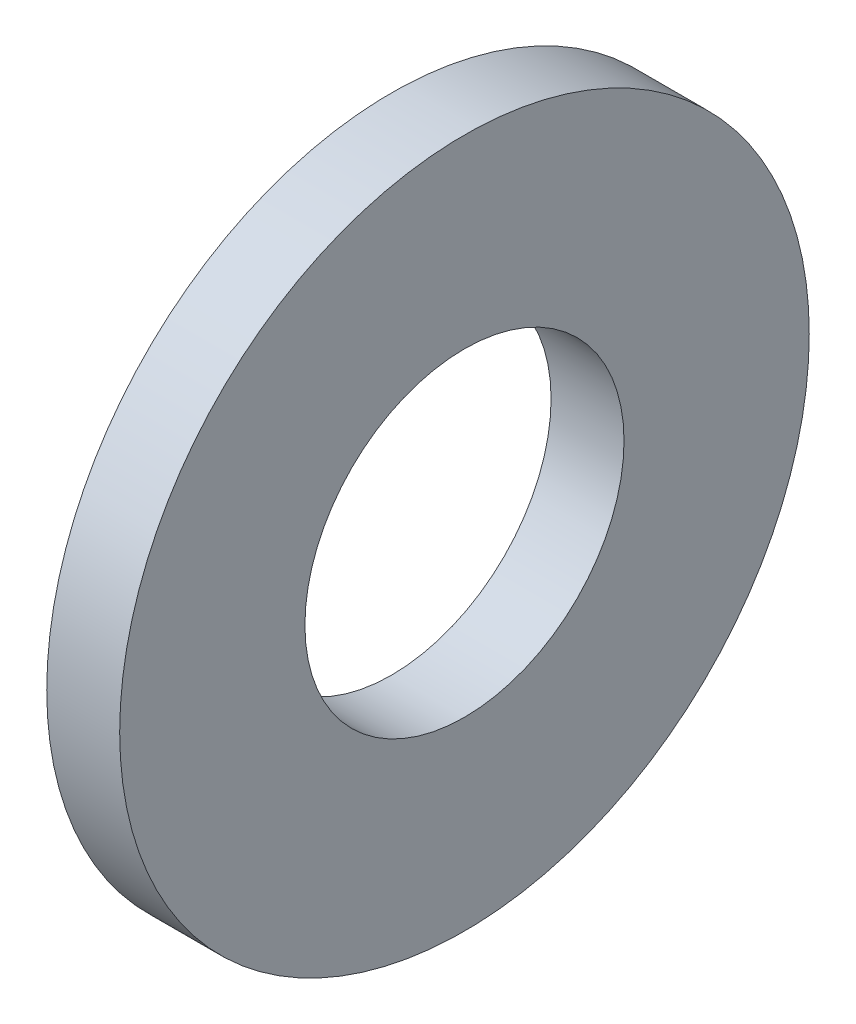
from build123d import *

# Parameters (mm, degrees)
SKETCH3_R                = 13
SKETCH3_R_2              = 6.016
BOSS_EXTRUDE1_DEPTH      = 1.375
BOSS_EXTRUDE1_DEPTH_BACK = 1.375


with BuildPart() as part:
    # Sketch3 → Boss-Extrude1 (new body, two sides)
    with BuildSketch(Plane(origin=(0, 0, 0), x_dir=(0, 0, -1), z_dir=(1, 0, 0))) as boss_extrude1_sk:
        Circle(SKETCH3_R)
        Circle(SKETCH3_R_2, mode=Mode.SUBTRACT)
    extrude(amount=BOSS_EXTRUDE1_DEPTH)
    extrude(boss_extrude1_sk.sketch, amount=-BOSS_EXTRUDE1_DEPTH_BACK)


solid = part.part
